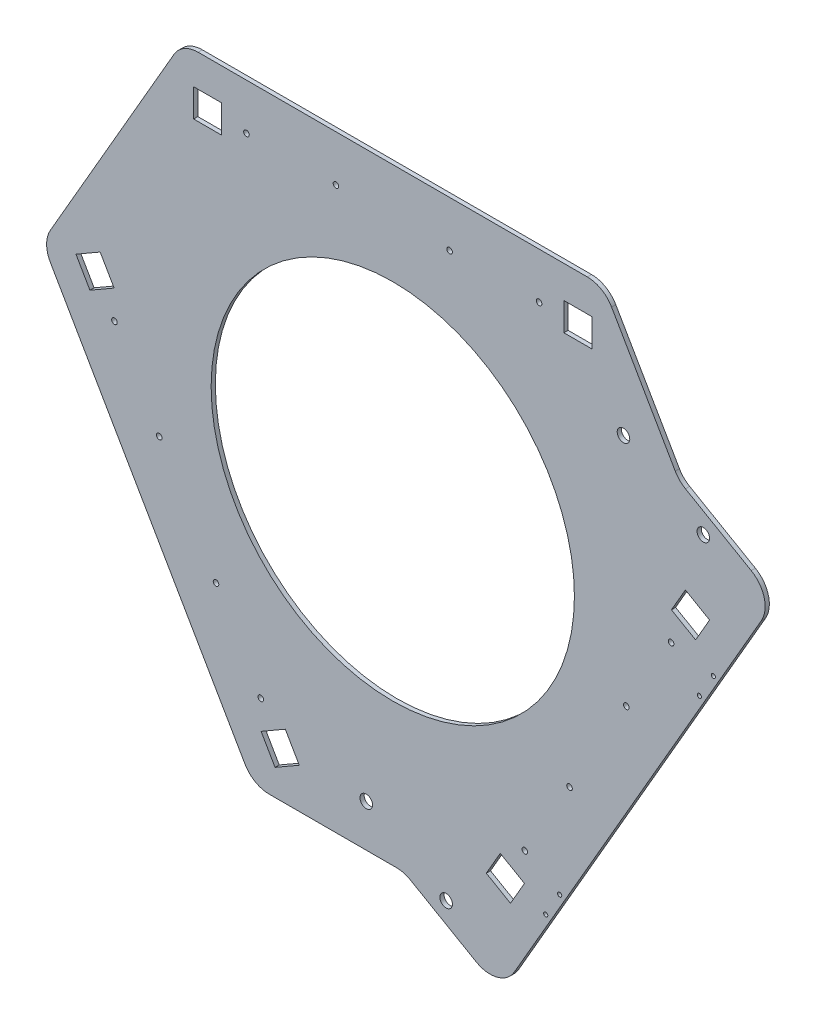
from build123d import *

# Parameters (mm, degrees)
SKETCH_1_R          = 130
SKETCH_1_R_2        = 2
SKETCH_1_R_3        = 1.5
EXTRUDE_1_DEPTH     = 3
SKETCH_8_W          = 20
SKETCH_8_H          = 20
CUT_EXTRUDE_4_DEPTH = 4
FILLET_2_R          = 20
EXTRUDE_2_DEPTH     = 3
FILLET_3_R          = 20
SKETCH_10_R         = 4.5
CUT_EXTRUDE_5_DEPTH = 3


with BuildPart() as part:
    # 草图1 → 凸台-拉伸1 (new body)
    with BuildSketch(Plane.XY):
        Polygon((150.828607906, 202.550991214), (-150.828607906, 202.550991214), (-250.828607906, 29.345910457), (-100, -231.89690167), (100, -231.89690167), (250.828607906, 29.345910457), align=None)
        Circle(SKETCH_1_R, mode=Mode.SUBTRACT)
        with Locations((-104.711767321, 169.550991214)):
            Circle(SKETCH_1_R_2, mode=Mode.SUBTRACT)
        with Locations((-40.666940629, 169.550991214)):
            Circle(SKETCH_1_R_2, mode=Mode.SUBTRACT)
        with Locations((40.666940629, 169.550991214)):
            Circle(SKETCH_1_R_2, mode=Mode.SUBTRACT)
        with Locations((104.711767321, 169.550991214)):
            Circle(SKETCH_1_R_2, mode=Mode.SUBTRACT)
        with Locations((94.479581967, -175.458546182)):
            Circle(SKETCH_1_R_2, mode=Mode.SUBTRACT)
        with Locations((126.501995314, -119.994099286)):
            Circle(SKETCH_1_R_2, mode=Mode.SUBTRACT)
        with Locations((167.168935942, -49.556891928)):
            Circle(SKETCH_1_R_2, mode=Mode.SUBTRACT)
        with Locations((199.191349289, 5.907554968)):
            Circle(SKETCH_1_R_2, mode=Mode.SUBTRACT)
        with Locations((-199.191349288, 5.907554969)):
            Circle(SKETCH_1_R_2, mode=Mode.SUBTRACT)
        with Locations((-167.168935942, -49.556891928)):
            Circle(SKETCH_1_R_2, mode=Mode.SUBTRACT)
        with Locations((-126.501995314, -119.994099285)):
            Circle(SKETCH_1_R_2, mode=Mode.SUBTRACT)
        with Locations((-94.479581968, -175.458546182)):
            Circle(SKETCH_1_R_2, mode=Mode.SUBTRACT)
        with Locations((109.450202338, -207.52867108)):
            Circle(SKETCH_1_R_3, mode=Mode.SUBTRACT)
        with Locations((119.450202338, -190.208163004)):
            Circle(SKETCH_1_R_3, mode=Mode.SUBTRACT)
        with Locations((219.450202338, -17.003082247)):
            Circle(SKETCH_1_R_3, mode=Mode.SUBTRACT)
        with Locations((229.450202338, 0.317425828)):
            Circle(SKETCH_1_R_3, mode=Mode.SUBTRACT)
    extrude(amount=EXTRUDE_1_DEPTH)

    # 草图8 → 切除-拉伸4 (cut, through all)
    with BuildSketch(Plane.XY.offset(3)):
        with Locations((-132.5, 169.550991214)):
            Rectangle(SKETCH_8_W, SKETCH_8_H)
        Polygon((-209.42521159, 43.633124432), (-226.745719666, 33.633124432), (-216.745719666, 16.312616357), (-199.42521159, 26.312616357), align=None)
        Polygon((-84.245719666, -213.184115646), (-66.92521159, -203.184115646), (-76.92521159, -185.86360757), (-94.245719666, -195.86360757), align=None)
        Polygon((66.92521159, -203.184115646), (84.245719666, -213.184115646), (94.245719666, -195.86360757), (76.92521159, -185.86360757), align=None)
        Polygon((209.42521159, 43.633124432), (199.42521159, 26.312616357), (216.745719666, 16.312616357), (226.745719666, 33.633124432), align=None)
        with Locations((132.5, 169.550991214)):
            Rectangle(SKETCH_8_W, SKETCH_8_H)
    extrude(amount=-CUT_EXTRUDE_4_DEPTH, mode=Mode.SUBTRACT)

    # 圆角2
    fillet_2_edges = [part.edges().sort_by_distance(p)[0] for p in [
        (-150.828607906, 202.550991214, 1.5),
        (150.828607906, 202.550991214, 1.5),
        (250.828607906, 29.345910457, 1.5),
        (100, -231.89690167, 1.5),
        (-100, -231.89690167, 1.5),
        (-250.828607906, 29.345910457, 1.5),
    ]]
    fillet(fillet_2_edges, radius=FILLET_2_R)

    # 草图9 → 凸台-拉伸2 (add)
    with BuildSketch(Plane.XY.offset(3)):
        with BuildLine():
            Line((88.452994616, -231.89690167), (8.007023849, -231.89690167))
            Line((8.007023849, -231.89690167), (77.001755962, -271.731028829))
            Line((77.001755962, -271.731028829), (105.773502692, -221.89690167))
            ThreePointArc((105.773502692, -221.89690167), (98.452994616, -229.217409746), (88.452994616, -231.89690167))
        make_face()
        with BuildLine():
            ThreePointArc((245.055105214, 39.345910457), (247.734597138, 29.345910457), (245.055105214, 19.345910457))
            Line((245.055105214, 19.345910457), (273.826851943, 69.180037615))
            Line((273.826851943, 69.180037615), (204.83211983, 109.014164773))
            Line((204.83211983, 109.014164773), (245.055105214, 39.345910457))
        make_face()
    extrude(amount=-EXTRUDE_2_DEPTH)

    # 圆角3
    fillet_3_edges = [part.edges().sort_by_distance(p)[0] for p in [
        (77.001755962, -271.731028829, 1.5),
        (8.007023849, -231.89690167, 1.5),
        (204.83211983, 109.014164773, 1.5),
        (273.826851943, 69.180037615, 1.5),
    ]]
    fillet(fillet_3_edges, radius=FILLET_3_R)

    # 草图10 → 切除-拉伸5 (cut)
    with BuildSketch(Plane.XY.offset(3)):
        with Locations((-18.973410903, -201.605578304)):
            Circle(SKETCH_10_R)
        with Locations((38.182680295, -234.604662943)):
            Circle(SKETCH_10_R)
        with Locations((165.108846905, 117.23424499)):
            Circle(SKETCH_10_R)
        with Locations((222.264938103, 84.235160351)):
            Circle(SKETCH_10_R)
    extrude(amount=-CUT_EXTRUDE_5_DEPTH, mode=Mode.SUBTRACT)


solid = part.part
